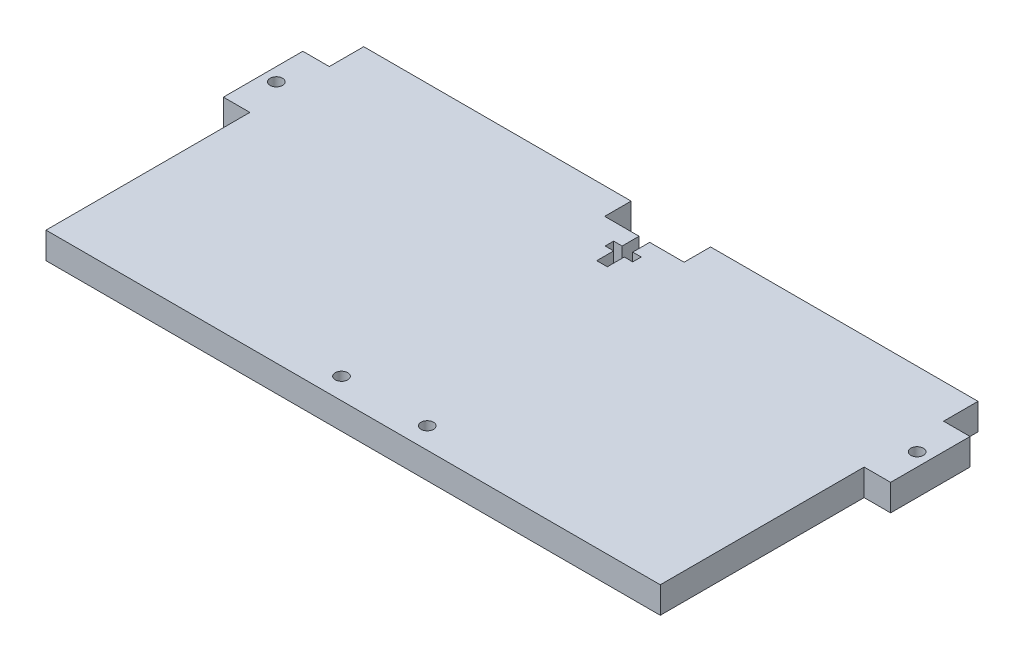
from build123d import *

# Parameters (mm, degrees)
SKETCH1_R           = 1.5
BOSS_EXTRUDE1_DEPTH = 6.35
SKETCH2_R           = 1.5
CUT_EXTRUDE1_DEPTH  = 7.35
CUT_EXTRUDE2_DEPTH  = 7.35


with BuildPart() as part:
    # Sketch1 → Boss-Extrude1 (new body)
    with BuildSketch(Plane(origin=(0, 0, 0), x_dir=(1, 0, 0), z_dir=(0, 1, 0))):
        Polygon((-73.66, -34.925), (73.66, -34.925), (73.66, 13.97), (80.01, 13.97), (80.01, 33.02), (73.66, 33.02), (73.66, 34.925), (73.66, 41.275), (9.525, 41.275), (9.525, 34.925), (-9.525, 34.925), (-9.525, 41.275), (-73.66, 41.275), (-73.66, 34.925), (-73.66, 33.02), (-80.01, 33.02), (-80.01, 13.97), (-73.66, 13.97), align=None)
        with Locations((-76.835, 23.495)):
            Circle(SKETCH1_R, mode=Mode.SUBTRACT)
        with Locations((76.835, 23.495)):
            Circle(SKETCH1_R, mode=Mode.SUBTRACT)
    extrude(amount=BOSS_EXTRUDE1_DEPTH)

    # Sketch2 → Cut-Extrude1 (cut, through all)
    with BuildSketch(Plane(origin=(0, 6.35, 0), x_dir=(1, 0, 0), z_dir=(0, 1, 0))):
        with Locations((12.7, -29.845)):
            Circle(SKETCH2_R)
        with Locations((-7.874, -29.845)):
            Circle(SKETCH2_R)
    extrude(amount=-CUT_EXTRUDE1_DEPTH, mode=Mode.SUBTRACT)

    # Sketch3 → Cut-Extrude2 (cut, through all)
    with BuildSketch(Plane(origin=(0, 6.35, 0), x_dir=(1, 0, 0), z_dir=(0, 1, 0))):
        Polygon((-1.27, 34.925), (1.27, 34.925), (1.27, 30.861), (3.302, 30.861), (3.302, 28.829), (1.27, 28.829), (1.27, 24.765), (-1.27, 24.765), (-1.27, 28.829), (-3.302, 28.829), (-3.302, 30.861), (-1.27, 30.861), align=None)
    extrude(amount=-CUT_EXTRUDE2_DEPTH, mode=Mode.SUBTRACT)


solid = part.part
